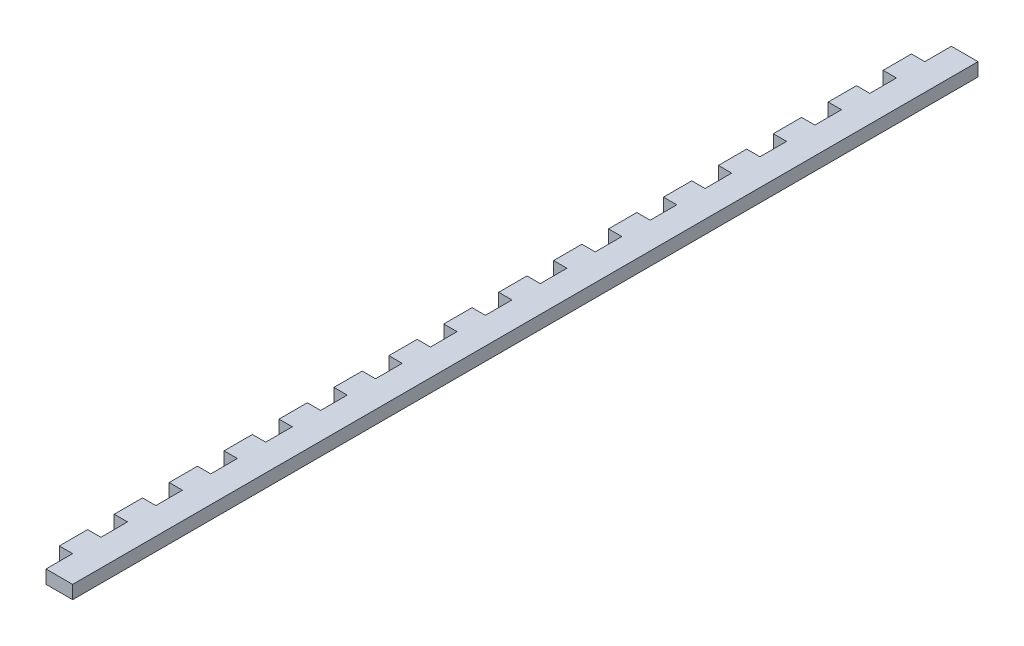
from build123d import *

# Parameters (mm, degrees)
SKETCH1_W           = 431.8
SKETCH1_H           = 285.75
BOSS_EXTRUDE1_DEPTH = 6.35
SKETCH2_W           = 431.8
SKETCH2_H           = 6.35
BOSS_EXTRUDE2_DEPTH = 12.7
CUT_EXTRUDE1_DEPTH  = 20.05
SKETCH5_W           = 33.462355894
SKETCH5_H           = 294.779483051
CUT_EXTRUDE2_DEPTH  = 432.8
SKETCH4_W           = 12.7
SKETCH4_H           = 6.35
CUT_EXTRUDE3_DEPTH  = 6.35


with BuildPart() as part:
    # Sketch1 → Boss-Extrude1 (new body)
    with BuildSketch(Plane(origin=(0, 0, 0), x_dir=(0, 0, -1), z_dir=(1, 0, 0))):
        Rectangle(SKETCH1_W, SKETCH1_H)
    extrude(amount=BOSS_EXTRUDE1_DEPTH)

    # Sketch2 → Boss-Extrude2 (add)
    with BuildSketch(Plane(origin=(6.35, 0, 0), x_dir=(0, 0, -1), z_dir=(1, 0, 0))):
        with Locations((0, 139.7)):
            Rectangle(SKETCH2_W, SKETCH2_H)
    extrude(amount=BOSS_EXTRUDE2_DEPTH)

    # Sketch3 → Cut-Extrude1 (cut, through all)
    with BuildSketch(Plane.ZY):
        with BuildLine():
            Line((-190.5, -85.725), (0, -85.725))
            ThreePointArc((0, -85.725), (12.7, -98.425), (0, -111.125))
            Line((0, -111.125), (-190.5, -111.125))
            ThreePointArc((-190.5, -111.125), (-203.2, -98.425), (-190.5, -85.725))
        make_face()
    extrude(amount=-CUT_EXTRUDE1_DEPTH, mode=Mode.SUBTRACT)

    # Sketch5 → Cut-Extrude2 (cut, through all)
    with BuildSketch(Plane(origin=(0, 0, -215.9), x_dir=(-1, 0, 0), z_dir=(0, 0, -1))):
        with Locations((10.381177947, -10.864741526)):
            Rectangle(SKETCH5_W, SKETCH5_H)
    extrude(amount=-CUT_EXTRUDE2_DEPTH, mode=Mode.SUBTRACT)

    # Sketch4 → Cut-Extrude3 (cut)
    with BuildSketch(Plane.ZY):
        with Locations((-183.35625, 139.7)):
            Rectangle(SKETCH4_W, SKETCH4_H)
        with Locations((-209.55, 139.7)):
            Rectangle(SKETCH4_W, SKETCH4_H)
        with Locations((-157.1625, 139.7)):
            Rectangle(SKETCH4_W, SKETCH4_H)
        with Locations((-130.96875, 139.7)):
            Rectangle(SKETCH4_W, SKETCH4_H)
        with Locations((-104.775, 139.7)):
            Rectangle(SKETCH4_W, SKETCH4_H)
        with Locations((-78.58125, 139.7)):
            Rectangle(SKETCH4_W, SKETCH4_H)
        with Locations((-52.3875, 139.7)):
            Rectangle(SKETCH4_W, SKETCH4_H)
        with Locations((-26.19375, 139.7)):
            Rectangle(SKETCH4_W, SKETCH4_H)
        with Locations((0, 139.7)):
            Rectangle(SKETCH4_W, SKETCH4_H)
        with Locations((26.19375, 139.7)):
            Rectangle(SKETCH4_W, SKETCH4_H)
        with Locations((52.3875, 139.7)):
            Rectangle(SKETCH4_W, SKETCH4_H)
        with Locations((78.58125, 139.7)):
            Rectangle(SKETCH4_W, SKETCH4_H)
        with Locations((104.775, 139.7)):
            Rectangle(SKETCH4_W, SKETCH4_H)
        with Locations((130.96875, 139.7)):
            Rectangle(SKETCH4_W, SKETCH4_H)
        with Locations((157.1625, 139.7)):
            Rectangle(SKETCH4_W, SKETCH4_H)
        with Locations((183.35625, 139.7)):
            Rectangle(SKETCH4_W, SKETCH4_H)
        with Locations((209.55, 139.7)):
            Rectangle(SKETCH4_W, SKETCH4_H)
    extrude(amount=-CUT_EXTRUDE3_DEPTH, mode=Mode.SUBTRACT)


solid = part.part
